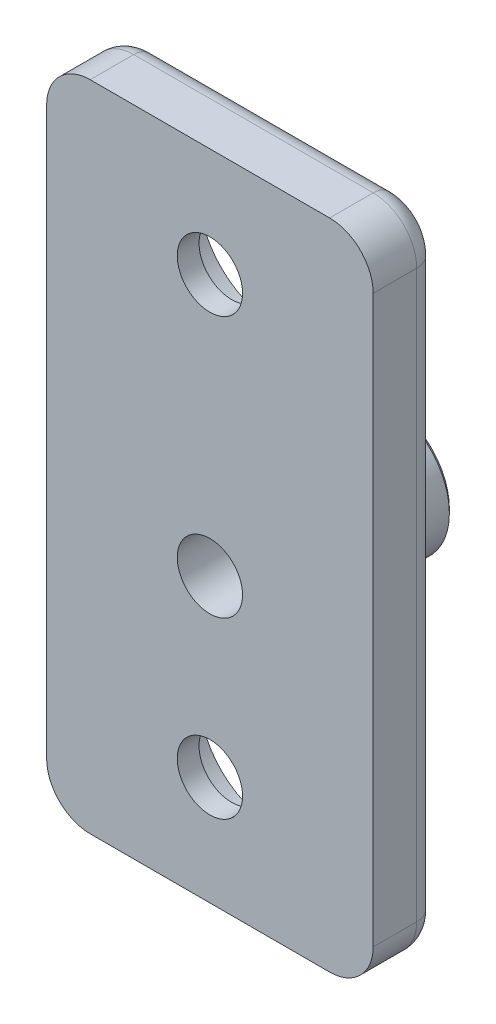
from build123d import *

# Parameters (mm, degrees)
ESQUISSE1_W                  = 15
ESQUISSE1_H                  = 30
BOSS_EXTRU_1_DEPTH           = 3
ESQUISSE2_R                  = 1.5
ENL_V_MAT_EXTRU_2_DEPTH      = 3
ESQUISSE3_R                  = 3.5
ENL_V_MAT_EXTRU_3_DEPTH      = 2
ESQUISSE4_R                  = 3
BOSS_EXTRU_2_DEPTH           = 5.2
CONG_3_R                     = 2
CONG_4_R                     = 1
ESQUISSE5_R                  = 1.5
ENL_V_MAT_EXTRU_4_DEPTH      = 18
ENL_V_MAT_EXTRU_4_DEPTH_BACK = 18
CHANFREIN2_SIZE              = 0.2


with BuildPart() as part:
    # Esquisse1 → Boss.-Extru.1 (new body)
    with BuildSketch(Plane.XY):
        with Locations((7.5, 15)):
            Rectangle(ESQUISSE1_W, ESQUISSE1_H)
    extrude(amount=BOSS_EXTRU_1_DEPTH)

    # Esquisse2 → Enlèv. mat.-Extru.2 (cut)
    with BuildSketch(Plane.XY):
        with Locations((7.5, 25)):
            Circle(ESQUISSE2_R)
        with Locations((7.5, 5)):
            Circle(ESQUISSE2_R)
    extrude(amount=ENL_V_MAT_EXTRU_2_DEPTH, mode=Mode.SUBTRACT)

    # Esquisse3 → Enlèv. mat.-Extru.3 (cut)
    with BuildSketch(Plane.XY):
        with Locations((7.5, 25)):
            Circle(ESQUISSE3_R)
        with Locations((7.5, 5)):
            Circle(ESQUISSE3_R)
    extrude(amount=ENL_V_MAT_EXTRU_3_DEPTH, mode=Mode.SUBTRACT)

    # Esquisse4 → Boss.-Extru.2 (add)
    with BuildSketch(Plane.XY):
        with Locations((7.5, 13)):
            Circle(ESQUISSE4_R)
    extrude(amount=-BOSS_EXTRU_2_DEPTH)

    # Congé3
    cong_3_edges = [part.edges().sort_by_distance(p)[0] for p in [
        (0, 30, 1.5),
        (15, 30, 1.5),
        (15, 0, 1.5),
        (0, 0, 1.5),
    ]]
    fillet(cong_3_edges, radius=CONG_3_R)

    # Congé4
    cong_4_edges = [part.edges().sort_by_distance(p)[0] for p in [
        (7.5, 30, 0),
        (0, 15, 0),
        (15, 15, 0),
        (7.5, 0, 0),
        (0.585786438, 29.414213562, 0),
        (0.585786438, 0.585786438, 0),
        (14.414213562, 0.585786438, 0),
        (14.414213562, 29.414213562, 0),
    ]]
    fillet(cong_4_edges, radius=CONG_4_R)

    # Esquisse5 → Enlèv. mat.-Extru.4 (cut, two sides)
    with BuildSketch(Plane.XY) as enl_v_mat_extru_4_sk:
        with Locations((7.5, 13)):
            Circle(ESQUISSE5_R)
    extrude(amount=ENL_V_MAT_EXTRU_4_DEPTH, mode=Mode.SUBTRACT)
    extrude(enl_v_mat_extru_4_sk.sketch, amount=-ENL_V_MAT_EXTRU_4_DEPTH_BACK, mode=Mode.SUBTRACT)

    # Chanfrein2
    chanfrein2_edges = [part.edges().sort_by_distance(p)[0] for p in [
        (4.5, 13, -5.2),
    ]]
    chamfer(chanfrein2_edges, length=CHANFREIN2_SIZE)


solid = part.part
